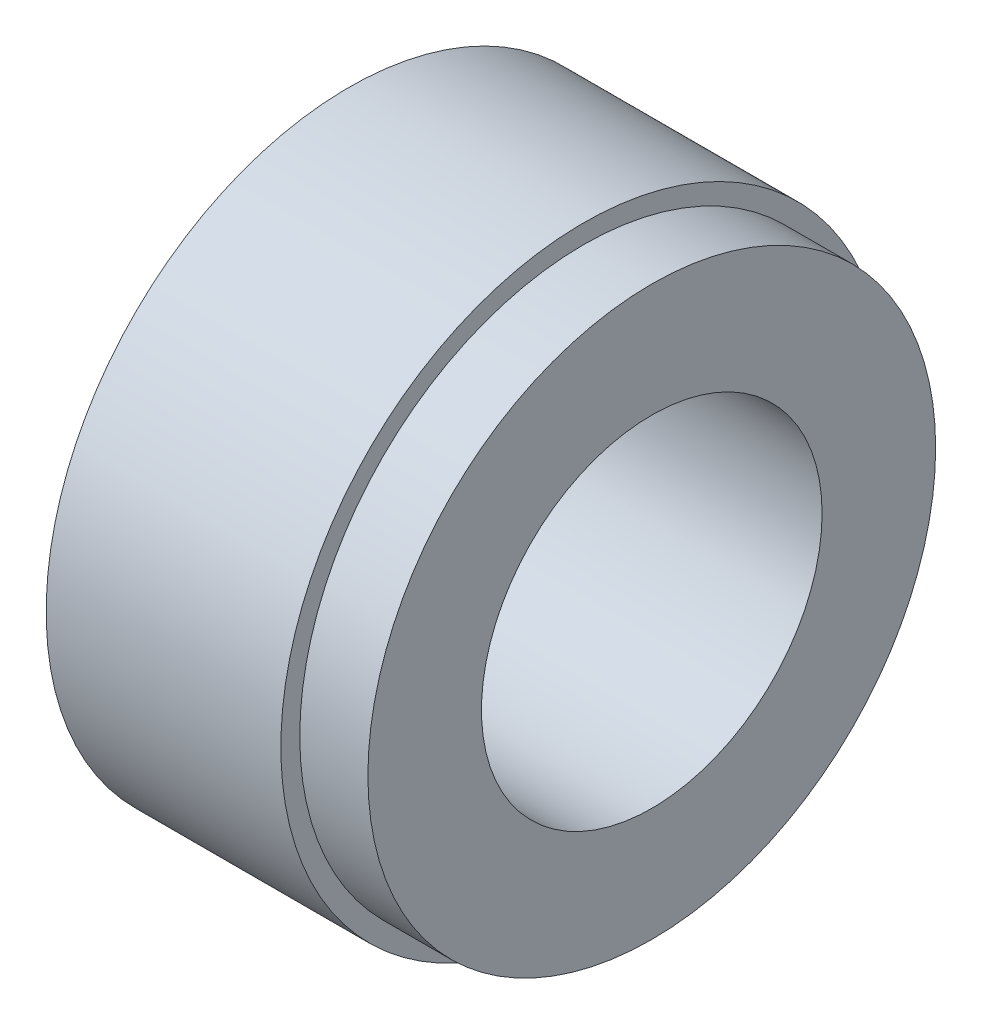
from build123d import *


with BuildPart() as part:
    # Sketch1 → Base-Revolve (revolve)
    with BuildSketch(Plane.XY):
        Polygon((0, 4.5), (0, 7.5), (-1.8, 7.5), (-1.8, 8), (-8, 8), (-8, 4.5), align=None)
    revolve(axis=Axis((0, 0, 0), (-1, 0, 0)))


solid = part.part
